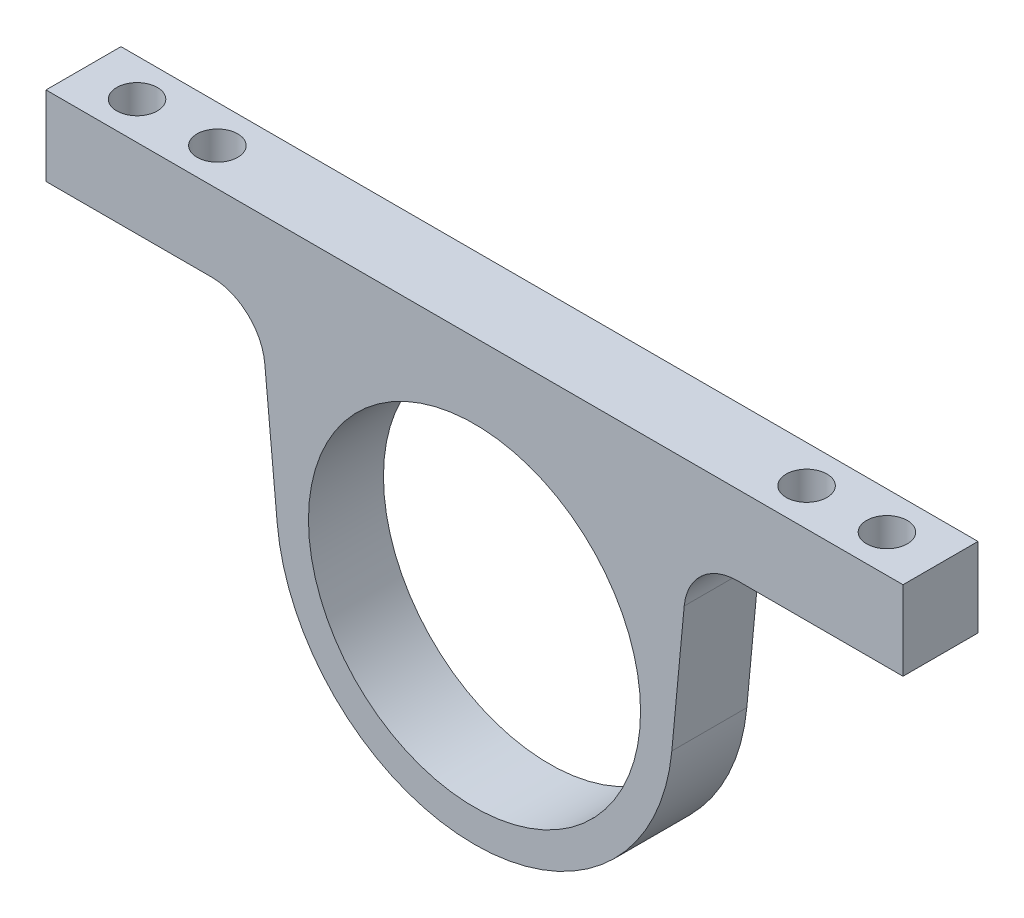
from build123d import *

# Parameters (mm, degrees)
SKETCH1_R                     = 31
BOSS_EXTRUDE1_DEPTH           = 7
FILLET1_R                     = 10
M7_CLEARANCE_HOLE1_AT_2_COUNT = 2
M7_CLEARANCE_HOLE1_AT_2_PITCH = 15


with BuildPart() as part:
    # Sketch1 → Boss-Extrude1 (new body, symmetric)
    with BuildSketch(Plane.XY):
        with BuildLine():
            Line((80, 45), (-80, 45))
            Line((-80, 45), (-80, 30.19235911))
            Line((-80, 30.19235911), (-40, 30.19235911))
            Line((-40, 30.19235911), (-36.83773054, -3.461446031))
            ThreePointArc((-36.83773054, -3.461446031), (0, -37), (36.83773054, -3.461446031))
            Line((36.83773054, -3.461446031), (40, 30.19235911))
            Line((40, 30.19235911), (80, 30.19235911))
            Line((80, 30.19235911), (80, 45))
        make_face()
        Circle(SKETCH1_R, mode=Mode.SUBTRACT)
    extrude(amount=BOSS_EXTRUDE1_DEPTH, both=True)

    # Fillet1
    fillet1_edges = [part.edges().sort_by_distance(p)[0] for p in [
        (-40, 30.19235911, 0),
        (40, 30.19235911, 0),
    ]]
    fillet(fillet1_edges, radius=FILLET1_R)

    # Sketch4 → M7 Clearance Hole1 (revolve, cut)
    with BuildSketch(Plane(origin=(-70, 45, 0), x_dir=(0, 0, 1), z_dir=(1, 0, 0))):
        Polygon((0, 0), (0, 22.033270352), (3.8, 19.75), (3.8, 0), align=None)
    m7_clearance_hole1 = revolve(axis=Axis((-70, 51.35, 0), (0, -1, 0)), mode=Mode.SUBTRACT)

    # M7 Clearance Hole1 at 2: M7 Clearance Hole1 ×2
    with Locations(*[(i * M7_CLEARANCE_HOLE1_AT_2_PITCH, 0, 0) for i in range(1, M7_CLEARANCE_HOLE1_AT_2_COUNT)]):
        add(m7_clearance_hole1, mode=Mode.SUBTRACT)

    # Mirror1: M7 Clearance Hole1 across plane
    add(m7_clearance_hole1.mirror(Plane(origin=(0, 0, 0), x_dir=(0, 0, 1), z_dir=(1, 0, 0))), mode=Mode.SUBTRACT)

    # Mirror1 copy 1 sketch → Mirror1 copy 1 (revolve, cut)
    with BuildSketch(Plane(origin=(55, 45, 0), x_dir=(0, 0, 1), z_dir=(-1, 0, 0))):
        Polygon((0, 0), (0, -22.033270352), (3.8, -19.75), (3.8, 0), align=None)
    revolve(axis=Axis((55, 51.35, 0), (0, 1, 0)), mode=Mode.SUBTRACT)


solid = part.part
